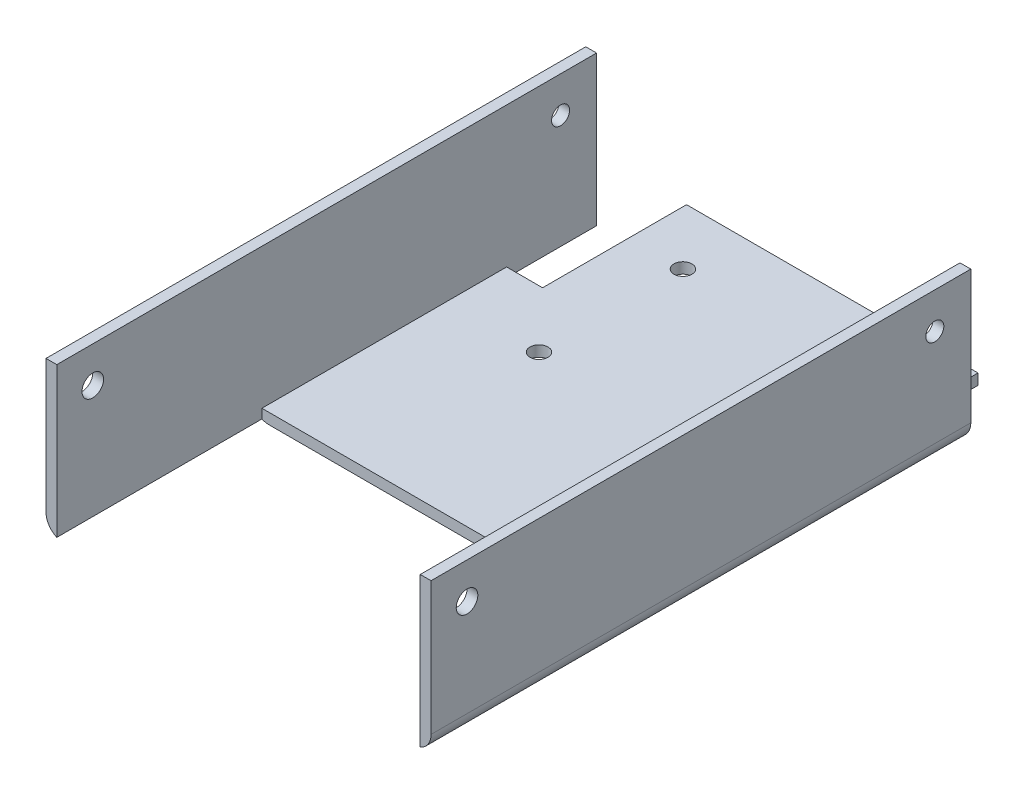
from build123d import *

# Parameters (mm, degrees)
SALIENTE_EXTRUIR1_DEPTH = 165
CROQUIS3_W              = 10
CROQUIS3_H              = 40
CORTAR_EXTRUIR1_DEPTH   = 165
CROQUIS4_W              = 3
CROQUIS4_H              = 15
CORTAR_EXTRUIR2_DEPTH   = 165
CROQUIS5_W              = 101
CROQUIS5_H              = 57
CORTAR_EXTRUIR3_DEPTH   = 165
CROQUIS6_R              = 2.5
CORTAR_EXTRUIR4_DEPTH   = 165
REDONDEO1_R             = 5
CROQUIS7_R              = 3
CORTAR_EXTRUIR5_DEPTH   = 110
CROQUIS8_R              = 2.5
CORTAR_EXTRUIR6_DEPTH   = 10


with BuildPart() as part:
    # Croquis2 → Saliente-Extruir1 (new body)
    with BuildSketch(Plane.XY):
        Polygon((61.739775044, 10), (61.739775044, -32), (-45.260224956, -32), (-45.260224956, 10), (-42.260224956, 10), (-42.260224956, -29), (58.739775044, -29), (58.739775044, 10), align=None)
    extrude(amount=SALIENTE_EXTRUIR1_DEPTH)

    # Croquis3 → Cortar-Extruir1 (cut)
    with BuildSketch(Plane(origin=(0, -29, 0), x_dir=(1, 0, 0), z_dir=(0, 1, 0))):
        with Locations((-37.260224956, -20)):
            Rectangle(CROQUIS3_W, CROQUIS3_H)
        with Locations((53.739775044, -20)):
            Rectangle(CROQUIS3_W, CROQUIS3_H)
    extrude(amount=-CORTAR_EXTRUIR1_DEPTH, mode=Mode.SUBTRACT)

    # Croquis4 → Cortar-Extruir2 (cut)
    with BuildSketch(Plane(origin=(0, 10, 0), x_dir=(1, 0, 0), z_dir=(0, 1, 0))):
        with Locations((-43.760224956, -7.5)):
            Rectangle(CROQUIS4_W, CROQUIS4_H)
        with Locations((60.239775044, -7.5)):
            Rectangle(CROQUIS4_W, CROQUIS4_H)
    extrude(amount=-CORTAR_EXTRUIR2_DEPTH, mode=Mode.SUBTRACT)

    # Croquis5 → Cortar-Extruir3 (cut)
    with BuildSketch(Plane(origin=(0, -29, 0), x_dir=(1, 0, 0), z_dir=(0, 1, 0))):
        with Locations((8.239775044, -136.5)):
            Rectangle(CROQUIS5_W, CROQUIS5_H)
    extrude(amount=-CORTAR_EXTRUIR3_DEPTH, mode=Mode.SUBTRACT)

    # Croquis6 → Cortar-Extruir4 (cut)
    with BuildSketch(Plane(origin=(61.739775044, 0, 0), x_dir=(0, 0, -1), z_dir=(1, 0, 0))):
        with Locations((-25, 0)):
            Circle(CROQUIS6_R)
        with Locations((-155, 0)):
            Circle(CROQUIS6_R)
    extrude(amount=-CORTAR_EXTRUIR4_DEPTH, mode=Mode.SUBTRACT)

    # Redondeo1
    redondeo1_edges = [part.edges().sort_by_distance(p)[0] for p in [
        (61.739775044, -32, 90),
        (-45.260224956, -32, 90),
    ]]
    fillet(redondeo1_edges, radius=REDONDEO1_R)

    # Croquis7 → Cortar-Extruir5 (cut)
    with BuildSketch(Plane(origin=(61.739775044, 0, 0), x_dir=(0, 0, -1), z_dir=(1, 0, 0))):
        with Locations((-155, 0)):
            Circle(CROQUIS7_R)
    extrude(amount=-CORTAR_EXTRUIR5_DEPTH, mode=Mode.SUBTRACT)

    # Croquis8 → Cortar-Extruir6 (cut)
    with BuildSketch(Plane(origin=(0, -29, 0), x_dir=(1, 0, 0), z_dir=(0, 1, 0))):
        with Locations((-17.260224956, -16)):
            Circle(CROQUIS8_R)
        with Locations((-17.260224956, -56)):
            Circle(CROQUIS8_R)
    extrude(amount=-CORTAR_EXTRUIR6_DEPTH, mode=Mode.SUBTRACT)


solid = part.part
